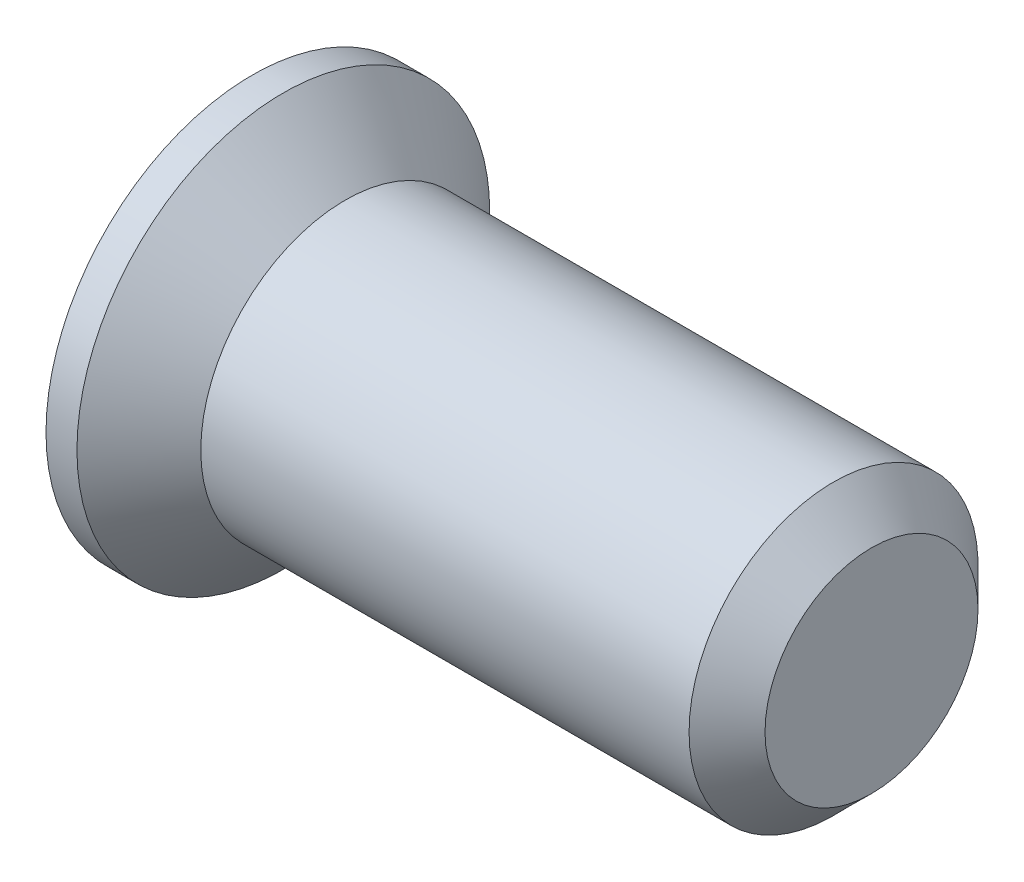
from build123d import *

# Parameters (mm, degrees)
CUT_EXTRUDE1_DEPTH      = 0.1
CUT_EXTRUDE1_DEPTH_BACK = 0.1
CUT_EXTRUDE2_DEPTH      = 0.1
CUT_EXTRUDE2_DEPTH_BACK = 0.1


with BuildPart() as part:
    # Sketch1 → Revolve1 (revolve)
    with BuildSketch(Plane.XY):
        Polygon((-0.45, 0), (-0.45, 1), (-0.3, 1), (0, 0.7), (2.366, 0.7), (2.55, 0.516), (2.55, 0), align=None)
    revolve(axis=Axis((2.55, 0, 0), (-1, 0, 0)))

    # Sketch2 → Cut-Extrude1 (cut, two sides: drawn at the far end of the back side and taken through both)
    with BuildSketch(Plane.XY.offset(-CUT_EXTRUDE1_DEPTH_BACK)):
        Polygon((-0.45, -0.6), (0.225, -0.3), (0.3375, 0), (0.225, 0.3), (-0.45, 0.6), align=None)
    extrude(amount=CUT_EXTRUDE1_DEPTH + CUT_EXTRUDE1_DEPTH_BACK, mode=Mode.SUBTRACT)

    # Sketch3 → Cut-Extrude2 (cut, two sides: drawn at the far end of the back side and taken through both)
    with BuildSketch(Plane(origin=(0, 0, 0), x_dir=(1, 0, 0), z_dir=(0, 1, 0)).offset(-CUT_EXTRUDE2_DEPTH_BACK)):
        Polygon((-0.45, -0.6), (0.225, -0.3), (0.3375, 0), (0.225, 0.3), (-0.45, 0.6), align=None)
    extrude(amount=CUT_EXTRUDE2_DEPTH + CUT_EXTRUDE2_DEPTH_BACK, mode=Mode.SUBTRACT)


solid = part.part
